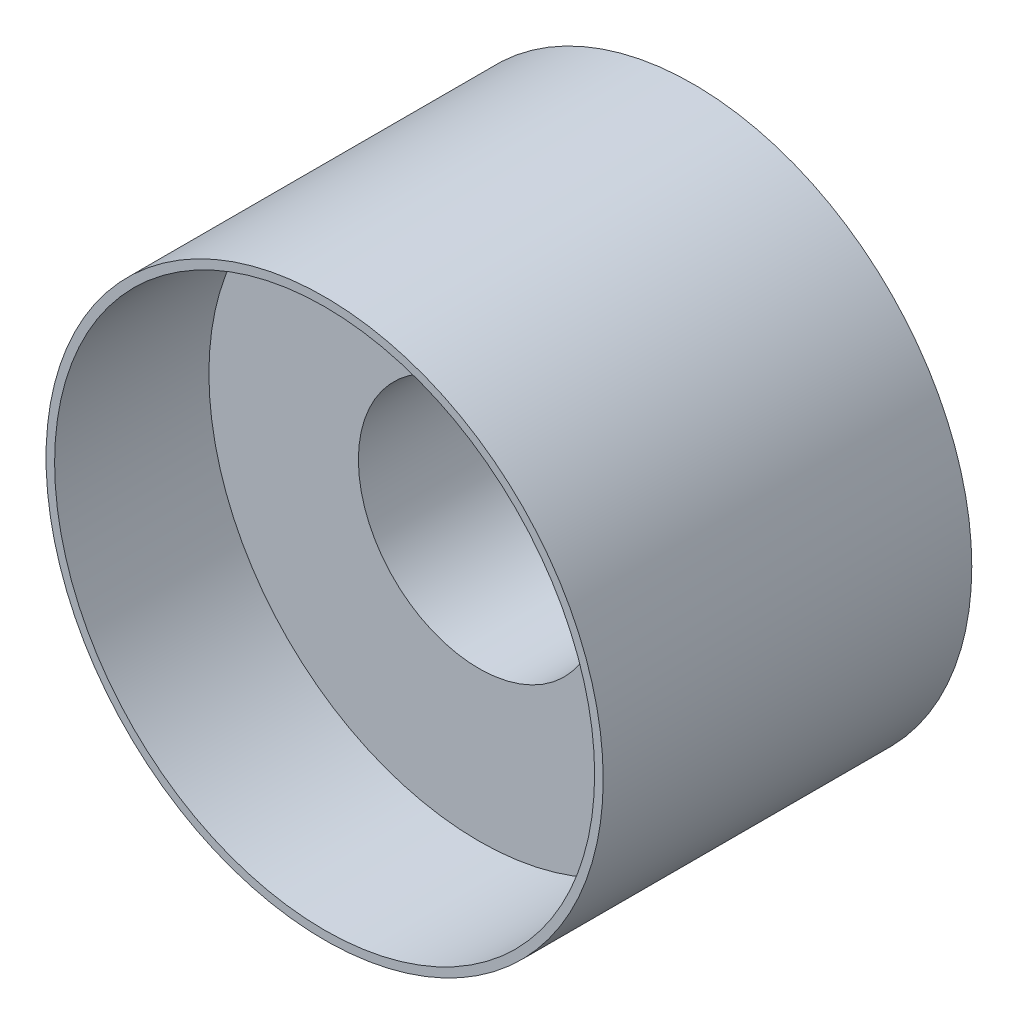
from build123d import *

# Parameters (mm, degrees)
SKETCH1_R           = 6.604
SKETCH1_R_2         = 6.4008
BOSS_EXTRUDE1_DEPTH = 8.7376
SKETCH2_R           = 6.4008
SKETCH2_R_2         = 2.8575
BOSS_EXTRUDE2_DEPTH = 5.08


with BuildPart() as part:
    # Sketch1 → Boss-Extrude1 (new body)
    with BuildSketch(Plane.XY):
        Circle(SKETCH1_R)
        Circle(SKETCH1_R_2, mode=Mode.SUBTRACT)
    extrude(amount=-BOSS_EXTRUDE1_DEPTH)

    # Sketch2 → Boss-Extrude2 (add)
    with BuildSketch(Plane(origin=(0, 0, -8.7376), x_dir=(-1, 0, 0), z_dir=(0, 0, -1))):
        Circle(SKETCH2_R)
        Circle(SKETCH2_R_2, mode=Mode.SUBTRACT)
    extrude(amount=-BOSS_EXTRUDE2_DEPTH)


solid = part.part
